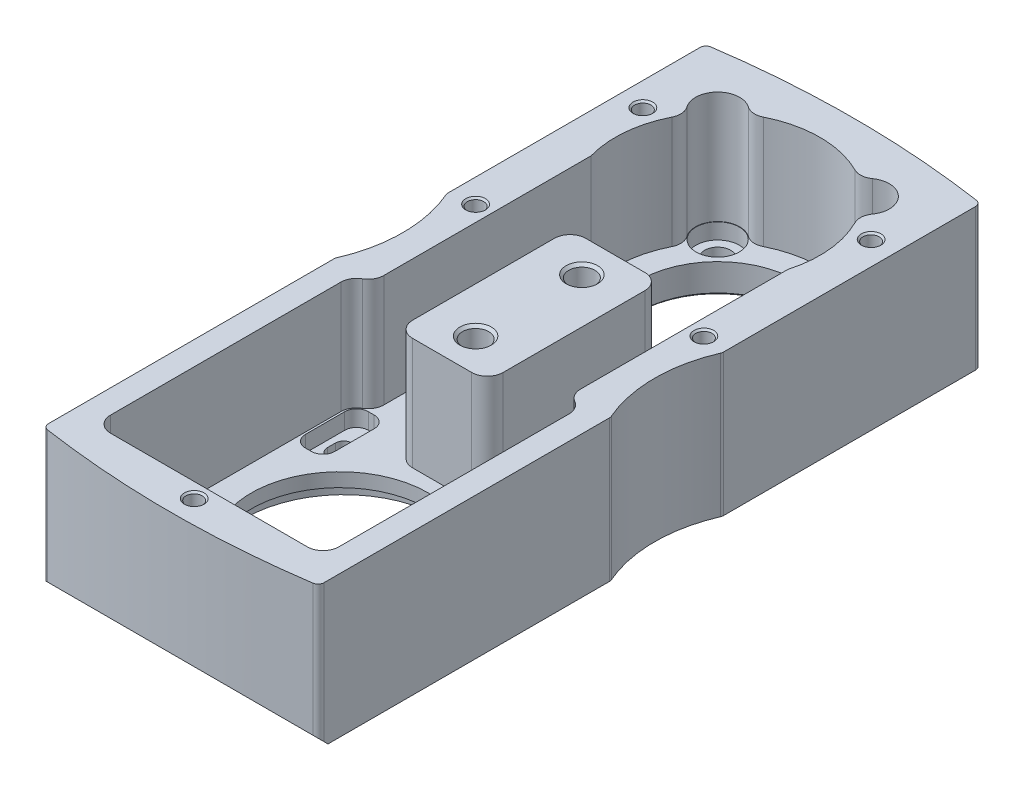
from build123d import *

# Parameters (mm, degrees)
BOSS_EXTRUDE1_DEPTH     = 36
CUT_EXTRUDE1_DEPTH      = 43
CUT_EXTRUDE1_DEPTH_BACK = 43
CUT_EXTRUDE2_DEPTH      = 32.6
CUT_EXTRUDE3_DEPTH      = 32.6
CUT_EXTRUDE4_DEPTH      = 32.6
CUT_EXTRUDE5_DEPTH      = 32.6
CUT_EXTRUDE6_DEPTH      = 36
CUT_EXTRUDE7_DEPTH      = 36
CUT_EXTRUDE8_DEPTH      = 36
CUT_EXTRUDE9_DEPTH      = 36
CUT_EXTRUDE10_DEPTH     = 4
SKETCH24_W              = 22.5
SKETCH24_H              = 36
CUT_EXTRUDE11_DEPTH     = 28.5


with BuildPart() as part:
    # Sketch1 → Boss-Extrude1 (new body)
    with BuildSketch(Plane(origin=(0, 0, 0), x_dir=(1, 0, 0), z_dir=(0, 1, 0))):
        with BuildLine():
            Line((-35, 76.508623254), (-35, 3.969028671))
            ThreePointArc((-35, 3.969028671), (-34.63575277, 2.989199275), (-33.719912473, 2.485236737))
            ThreePointArc((-33.719912473, 2.485236737), (0, 0), (33.719912473, 2.485236737))
            ThreePointArc((33.719912473, 2.485236737), (34.63575277, 2.989199275), (35, 3.969028671))
            Line((35, 3.969028671), (35, 76.508623254))
            ThreePointArc((35, 76.508623254), (34.96885474, 76.812705074), (34.876712329, 77.104159284))
            ThreePointArc((34.876712329, 77.104159284), (32, 91), (34.876712329, 104.895840716))
            ThreePointArc((34.876712329, 104.895840716), (34.96885474, 105.187294926), (35, 105.491376746))
            Line((35, 105.491376746), (35, 169.530971329))
            ThreePointArc((35, 169.530971329), (34.63575277, 170.510800725), (33.719912473, 171.014763263))
            ThreePointArc((33.719912473, 171.014763263), (0, 173.5), (-33.719912473, 171.014763263))
            ThreePointArc((-33.719912473, 171.014763263), (-34.63575277, 170.510800725), (-35, 169.530971329))
            Line((-35, 169.530971329), (-35, 105.491376746))
            ThreePointArc((-35, 105.491376746), (-34.96885474, 105.187294926), (-34.876712329, 104.895840716))
            ThreePointArc((-34.876712329, 104.895840716), (-32, 91), (-34.876712329, 77.104159284))
            ThreePointArc((-34.876712329, 77.104159284), (-34.96885474, 76.812705074), (-35, 76.508623254))
        make_face()
    extrude(amount=BOSS_EXTRUDE1_DEPTH)

    # Sketch2 → Cut-Extrude1 (cut, two sides: drawn at the far end of the back side and taken through both)
    with BuildSketch(Plane(origin=(0, 0, 0), x_dir=(0, 0, -1), z_dir=(1, 0, 0)).offset(-CUT_EXTRUDE1_DEPTH_BACK)):
        Polygon((0, 5), (0, 0), (5, 0), align=None)
    extrude(amount=CUT_EXTRUDE1_DEPTH + CUT_EXTRUDE1_DEPTH_BACK, mode=Mode.SUBTRACT)

    # Sketch3 → Cut-Revolve1 (revolve, cut)
    with BuildSketch(Plane(origin=(0, 0, 0), x_dir=(0, 0, -1), z_dir=(1, 0, 0))):
        Polygon((104.5, 36), (108.5, 36), (107.8235, 35.3235), (107.8235, 6), (104.5, 4.08117638), align=None)
    revolve(axis=Axis((0, 4.08117638, -104.5), (0, 1, 0)), mode=Mode.SUBTRACT)

    # Sketch4 → Cut-Revolve2 (revolve, cut)
    with BuildSketch(Plane(origin=(0, 0, 0), x_dir=(0, 0, -1), z_dir=(1, 0, 0))):
        Polygon((77.5, 36), (81.5, 36), (80.8235, 35.3235), (80.8235, 6), (77.5, 4.08117638), align=None)
    revolve(axis=Axis((0, 4.08117638, -77.5), (0, 1, 0)), mode=Mode.SUBTRACT)

    # Sketch5 → Cut-Revolve3 (revolve, cut)
    with BuildSketch(Plane(origin=(-29, 0, 0), x_dir=(0, 0, -1), z_dir=(1, 0, 0))):
        Polygon((149, 36), (151.5, 36), (151.067, 35.567), (151.067, 18), (149, 16.806616994), align=None)
    revolve(axis=Axis((-29, 16.806616994, -149), (0, 1, 0)), mode=Mode.SUBTRACT)

    # Sketch6 → Cut-Revolve4 (revolve, cut)
    with BuildSketch(Plane(origin=(-29, 0, 0), x_dir=(0, 0, -1), z_dir=(1, 0, 0))):
        Polygon((106.5, 36), (109, 36), (108.567, 35.567), (108.567, 18), (106.5, 16.806616994), align=None)
    revolve(axis=Axis((-29, 16.806616994, -106.5), (0, 1, 0)), mode=Mode.SUBTRACT)

    # Sketch7 → Cut-Revolve5 (revolve, cut)
    with BuildSketch(Plane(origin=(29, 0, 0), x_dir=(0, 0, -1), z_dir=(1, 0, 0))):
        Polygon((149, 36), (151.5, 36), (151.067, 35.567), (151.067, 18), (149, 16.806616994), align=None)
    revolve(axis=Axis((29, 16.806616994, -149), (0, 1, 0)), mode=Mode.SUBTRACT)

    # Sketch8 → Cut-Revolve6 (revolve, cut)
    with BuildSketch(Plane(origin=(29, 0, 0), x_dir=(0, 0, -1), z_dir=(1, 0, 0))):
        Polygon((106.5, 36), (109, 36), (108.567, 35.567), (108.567, 18), (106.5, 16.806616994), align=None)
    revolve(axis=Axis((29, 16.806616994, -106.5), (0, 1, 0)), mode=Mode.SUBTRACT)

    # Sketch9 → Cut-Revolve7 (revolve, cut)
    with BuildSketch(Plane(origin=(0, 0, 0), x_dir=(0, 0, -1), z_dir=(1, 0, 0))):
        Polygon((6, 36), (8.5, 36), (8.067, 35.567), (8.067, 18), (6, 16.806616994), align=None)
    revolve(axis=Axis((0, 16.806616994, -6), (0, 1, 0)), mode=Mode.SUBTRACT)

    # Sketch10 → Cut-Revolve8 (revolve, cut)
    with BuildSketch(Plane(origin=(0, 0, 0), x_dir=(0, 0, -1), z_dir=(1, 0, 0))):
        Polygon((139, 36), (159, 36), (159, 0.6), (159.6, 0), (139, 0), align=None)
    revolve(axis=Axis((0, 0, -139), (0, 1, 0)), mode=Mode.SUBTRACT)

    # Sketch11 → Cut-Revolve9 (revolve, cut)
    with BuildSketch(Plane(origin=(19, 0, 0), x_dir=(0, 0, -1), z_dir=(1, 0, 0))):
        Polygon((120, 36), (125.5, 36), (125.5, 3.5), (123.3, 3.5), (123.3, 0), (120, 0), align=None)
    revolve(axis=Axis((19, 0, -120), (0, 1, 0)), mode=Mode.SUBTRACT)

    # Sketch12 → Cut-Revolve10 (revolve, cut)
    with BuildSketch(Plane(origin=(19, 0, 0), x_dir=(0, 0, -1), z_dir=(1, 0, 0))):
        Polygon((158, 36), (163.5, 36), (163.5, 3.5), (161.3, 3.5), (161.3, 0), (158, 0), align=None)
    revolve(axis=Axis((19, 0, -158), (0, 1, 0)), mode=Mode.SUBTRACT)

    # Sketch13 → Cut-Revolve11 (revolve, cut)
    with BuildSketch(Plane(origin=(-19, 0, 0), x_dir=(0, 0, -1), z_dir=(1, 0, 0))):
        Polygon((120, 36), (125.5, 36), (125.5, 3.5), (123.3, 3.5), (123.3, 0), (120, 0), align=None)
    revolve(axis=Axis((-19, 0, -120), (0, 1, 0)), mode=Mode.SUBTRACT)

    # Sketch14 → Cut-Revolve12 (revolve, cut)
    with BuildSketch(Plane(origin=(-19, 0, 0), x_dir=(0, 0, -1), z_dir=(1, 0, 0))):
        Polygon((158, 36), (163.5, 36), (163.5, 3.5), (161.3, 3.5), (161.3, 0), (158, 0), align=None)
    revolve(axis=Axis((-19, 0, -158), (0, 1, 0)), mode=Mode.SUBTRACT)

    # Sketch15 → Cut-Extrude2 (cut)
    with BuildSketch(Plane(origin=(0, 36, 0), x_dir=(1, 0, 0), z_dir=(0, 1, 0))):
        with BuildLine():
            Line((23.998737342, 10.251262658), (25.498737342, 10.251262658))
            ThreePointArc((25.498737342, 10.251262658), (27.620057685, 11.129942315), (28.498737342, 13.251262658))
            Line((28.498737342, 13.251262658), (28.498737342, 23.251262658))
            ThreePointArc((28.498737342, 23.251262658), (27.620057685, 25.372583002), (25.498737342, 26.251262658))
            Line((25.498737342, 26.251262658), (23.998737342, 26.251262658))
            ThreePointArc((23.998737342, 26.251262658), (21.877416998, 25.372583002), (20.998737342, 23.251262658))
            Line((20.998737342, 23.251262658), (20.998737342, 13.251262658))
            ThreePointArc((20.998737342, 13.251262658), (21.877416998, 11.129942315), (23.998737342, 10.251262658))
        make_face()
    extrude(amount=-CUT_EXTRUDE2_DEPTH, mode=Mode.SUBTRACT)

    # Sketch16 → Cut-Extrude3 (cut)
    with BuildSketch(Plane(origin=(0, 36, 0), x_dir=(1, 0, 0), z_dir=(0, 1, 0))):
        with BuildLine():
            Line((23.998737342, 59.748737342), (25.498737342, 59.748737342))
            ThreePointArc((25.498737342, 59.748737342), (27.620057685, 60.627416998), (28.498737342, 62.748737342))
            Line((28.498737342, 62.748737342), (28.498737342, 72.748737342))
            ThreePointArc((28.498737342, 72.748737342), (27.620057685, 74.870057685), (25.498737342, 75.748737342))
            Line((25.498737342, 75.748737342), (23.998737342, 75.748737342))
            ThreePointArc((23.998737342, 75.748737342), (21.877416998, 74.870057685), (20.998737342, 72.748737342))
            Line((20.998737342, 72.748737342), (20.998737342, 62.748737342))
            ThreePointArc((20.998737342, 62.748737342), (21.877416998, 60.627416998), (23.998737342, 59.748737342))
        make_face()
    extrude(amount=-CUT_EXTRUDE3_DEPTH, mode=Mode.SUBTRACT)

    # Sketch17 → Cut-Extrude4 (cut)
    with BuildSketch(Plane(origin=(0, 36, 0), x_dir=(1, 0, 0), z_dir=(0, 1, 0))):
        with BuildLine():
            Line((-25.498737342, 59.748737342), (-23.998737342, 59.748737342))
            ThreePointArc((-23.998737342, 59.748737342), (-21.877416998, 60.627416998), (-20.998737342, 62.748737342))
            Line((-20.998737342, 62.748737342), (-20.998737342, 72.748737342))
            ThreePointArc((-20.998737342, 72.748737342), (-21.877416998, 74.870057685), (-23.998737342, 75.748737342))
            Line((-23.998737342, 75.748737342), (-25.498737342, 75.748737342))
            ThreePointArc((-25.498737342, 75.748737342), (-27.620057685, 74.870057685), (-28.498737342, 72.748737342))
            Line((-28.498737342, 72.748737342), (-28.498737342, 62.748737342))
            ThreePointArc((-28.498737342, 62.748737342), (-27.620057685, 60.627416998), (-25.498737342, 59.748737342))
        make_face()
    extrude(amount=-CUT_EXTRUDE4_DEPTH, mode=Mode.SUBTRACT)

    # Sketch18 → Cut-Extrude5 (cut)
    with BuildSketch(Plane(origin=(0, 36, 0), x_dir=(1, 0, 0), z_dir=(0, 1, 0))):
        with BuildLine():
            Line((-25.498737342, 10.251262658), (-23.998737342, 10.251262658))
            ThreePointArc((-23.998737342, 10.251262658), (-21.877416998, 11.129942315), (-20.998737342, 13.251262658))
            Line((-20.998737342, 13.251262658), (-20.998737342, 23.251262658))
            ThreePointArc((-20.998737342, 23.251262658), (-21.877416998, 25.372583002), (-23.998737342, 26.251262658))
            Line((-23.998737342, 26.251262658), (-25.498737342, 26.251262658))
            ThreePointArc((-25.498737342, 26.251262658), (-27.620057685, 25.372583002), (-28.498737342, 23.251262658))
            Line((-28.498737342, 23.251262658), (-28.498737342, 13.251262658))
            ThreePointArc((-28.498737342, 13.251262658), (-27.620057685, 11.129942315), (-25.498737342, 10.251262658))
        make_face()
    extrude(amount=-CUT_EXTRUDE5_DEPTH, mode=Mode.SUBTRACT)

    # Sketch19 → Cut-Extrude6 (cut)
    with BuildSketch(Plane(origin=(0, 36, 0), x_dir=(1, 0, 0), z_dir=(0, 1, 0))):
        with BuildLine():
            Line((26.898737342, 17.251262658), (26.898737342, 19.251262658))
            ThreePointArc((26.898737342, 19.251262658), (24.748737342, 21.401262658), (22.598737342, 19.251262658))
            Line((22.598737342, 19.251262658), (22.598737342, 17.251262658))
            ThreePointArc((22.598737342, 17.251262658), (24.748737342, 15.101262658), (26.898737342, 17.251262658))
        make_face()
    extrude(amount=-CUT_EXTRUDE6_DEPTH, mode=Mode.SUBTRACT)

    # Sketch20 → Cut-Extrude7 (cut)
    with BuildSketch(Plane(origin=(0, 36, 0), x_dir=(1, 0, 0), z_dir=(0, 1, 0))):
        with BuildLine():
            Line((26.898737342, 66.748737342), (26.898737342, 68.748737342))
            ThreePointArc((26.898737342, 68.748737342), (24.748737342, 70.898737342), (22.598737342, 68.748737342))
            Line((22.598737342, 68.748737342), (22.598737342, 66.748737342))
            ThreePointArc((22.598737342, 66.748737342), (24.748737342, 64.598737342), (26.898737342, 66.748737342))
        make_face()
    extrude(amount=-CUT_EXTRUDE7_DEPTH, mode=Mode.SUBTRACT)

    # Sketch21 → Cut-Extrude8 (cut)
    with BuildSketch(Plane(origin=(0, 36, 0), x_dir=(1, 0, 0), z_dir=(0, 1, 0))):
        with BuildLine():
            Line((-22.598737342, 66.748737342), (-22.598737342, 68.748737342))
            ThreePointArc((-22.598737342, 68.748737342), (-24.748737342, 70.898737342), (-26.898737342, 68.748737342))
            Line((-26.898737342, 68.748737342), (-26.898737342, 66.748737342))
            ThreePointArc((-26.898737342, 66.748737342), (-24.748737342, 64.598737342), (-22.598737342, 66.748737342))
        make_face()
    extrude(amount=-CUT_EXTRUDE8_DEPTH, mode=Mode.SUBTRACT)

    # Sketch22 → Cut-Extrude9 (cut)
    with BuildSketch(Plane(origin=(0, 36, 0), x_dir=(1, 0, 0), z_dir=(0, 1, 0))):
        with BuildLine():
            Line((-22.598737342, 17.251262658), (-22.598737342, 19.251262658))
            ThreePointArc((-22.598737342, 19.251262658), (-24.748737342, 21.401262658), (-26.898737342, 19.251262658))
            Line((-26.898737342, 19.251262658), (-26.898737342, 17.251262658))
            ThreePointArc((-26.898737342, 17.251262658), (-24.748737342, 15.101262658), (-22.598737342, 17.251262658))
        make_face()
    extrude(amount=-CUT_EXTRUDE9_DEPTH, mode=Mode.SUBTRACT)

    # Sketch23 → Cut-Extrude10 (cut)
    with BuildSketch(Plane(origin=(0, 0, 0), x_dir=(1, 0, 0), z_dir=(0, 1, 0))):
        with BuildLine():
            Line((25.25, 42), (25.25, 44))
            ThreePointArc((25.25, 44), (0, 69.25), (-25.25, 44))
            Line((-25.25, 44), (-25.25, 42))
            ThreePointArc((-25.25, 42), (0, 16.75), (25.25, 42))
        make_face()
    extrude(amount=CUT_EXTRUDE10_DEPTH, mode=Mode.SUBTRACT)

    # Sketch24 → Cut-Revolve13 (revolve, cut)
    with BuildSketch(Plane(origin=(0, 0, 0), x_dir=(0, 0, -1), z_dir=(1, 0, 0))):
        with Locations((54.25, 18)):
            Rectangle(SKETCH24_W, SKETCH24_H)
    revolve(axis=Axis((0, 0, -43), (0, 1, 0)), mode=Mode.SUBTRACT)

    # Sketch25 → Cut-Extrude11 (cut)
    with BuildSketch(Plane(origin=(0, 36, 0), x_dir=(1, 0, 0), z_dir=(0, 1, 0))):
        with BuildLine():
            Line((-24.998737342, 9.751262658), (24.998737342, 9.751262658))
            ThreePointArc((24.998737342, 9.751262658), (27.827164466, 10.922835534), (28.998737342, 13.751262658))
            Line((28.998737342, 13.751262658), (28.998737342, 72.248737342))
            ThreePointArc((28.998737342, 72.248737342), (28.463021201, 74.248421652), (26.999368671, 75.712474382))
            ThreePointArc((26.999368671, 75.712474382), (25.535716141, 77.176527112), (25, 79.176211422))
            Line((25, 79.176211422), (25, 131.858571571))
            ThreePointArc((25, 131.858571571), (25.887491435, 141.41615132), (23.246664393, 150.644423326))
            ThreePointArc((23.246664393, 150.644423326), (22.834904967, 152.74329034), (23.563460008, 154.75425929))
            ThreePointArc((23.563460008, 154.75425929), (22.959797975, 161.959797975), (15.75425929, 162.563460008))
            ThreePointArc((15.75425929, 162.563460008), (13.74329034, 161.834904967), (11.644423326, 162.246664393))
            ThreePointArc((11.644423326, 162.246664393), (0, 165), (-11.644423326, 162.246664393))
            ThreePointArc((-11.644423326, 162.246664393), (-13.74329034, 161.834904967), (-15.75425929, 162.563460008))
            ThreePointArc((-15.75425929, 162.563460008), (-22.959797975, 161.959797975), (-23.563460008, 154.75425929))
            ThreePointArc((-23.563460008, 154.75425929), (-22.834904967, 152.74329034), (-23.246664393, 150.644423326))
            ThreePointArc((-23.246664393, 150.644423326), (-25.887491435, 141.41615132), (-25, 131.858571571))
            Line((-25, 131.858571571), (-25, 79.176211422))
            ThreePointArc((-25, 79.176211422), (-25.535716141, 77.176527112), (-26.999368671, 75.712474382))
            ThreePointArc((-26.999368671, 75.712474382), (-28.463021201, 74.248421652), (-28.998737342, 72.248737342))
            Line((-28.998737342, 72.248737342), (-28.998737342, 13.751262658))
            ThreePointArc((-28.998737342, 13.751262658), (-27.827164466, 10.922835534), (-24.998737342, 9.751262658))
        make_face()
        with BuildLine():
            Line((-11.5, 109), (-11.5, 73))
            ThreePointArc((-11.5, 73), (-10.328427125, 70.171572875), (-7.5, 69))
            Line((-7.5, 69), (7.5, 69))
            ThreePointArc((7.5, 69), (10.328427125, 70.171572875), (11.5, 73))
            Line((11.5, 73), (11.5, 109))
            ThreePointArc((11.5, 109), (10.328427125, 111.828427125), (7.5, 113))
            Line((7.5, 113), (-7.5, 113))
            ThreePointArc((-7.5, 113), (-10.328427125, 111.828427125), (-11.5, 109))
        make_face(mode=Mode.SUBTRACT)
    extrude(amount=-CUT_EXTRUDE11_DEPTH, mode=Mode.SUBTRACT)


solid = part.part
